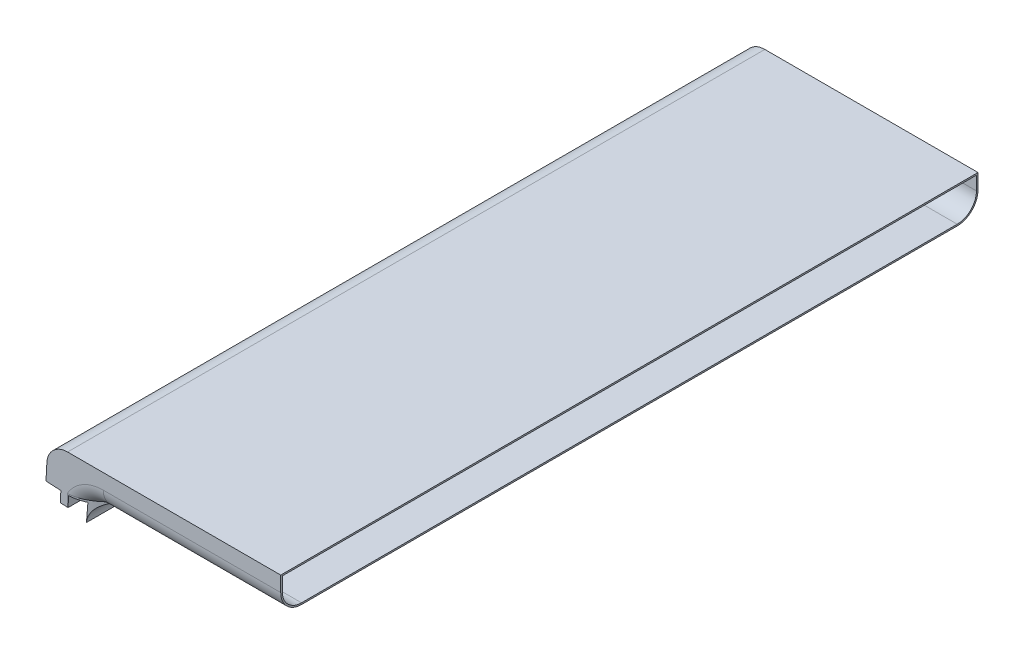
from build123d import *

# Parameters (mm, degrees)
BOSS_EXTRUDE1_DEPTH = 450
FILLET1_R           = 13.4
BOSS_EXTRUDE2_DEPTH = 450
FILLET2_R           = 13.4
CUT_EXTRUDE1_DEPTH  = 451.0000001
SHELL1_T            = -1
BOSS_EXTRUDE3_DEPTH = 450
CUT_EXTRUDE2_DEPTH  = 13.698698186


with BuildPart() as part:
    # Sketch2 → Boss-Extrude1 (new body)
    with BuildSketch(Plane.XY):
        Polygon((0, 0), (151.490860479, 0), (151.490860479, 23.2), (1.215860479, 23.2), align=None)
    extrude(amount=BOSS_EXTRUDE1_DEPTH)

    # Fillet1
    fillet1_edges = [part.edges().sort_by_distance(p)[0] for p in [
        (1.215860479, 23.2, 225),
    ]]
    fillet(fillet1_edges, radius=FILLET1_R)

    # Sketch4 → Boss-Extrude2 (add, through all)
    with BuildSketch(Plane.XY.offset(450)):
        with BuildLine():
            Line((24.166834741, -1.266530141), (23.567700201, -12.698698186))
            ThreePointArc((23.567700201, -12.698698186), (27.725384653, -3.679983428), (36.949335967, 0))
            Line((36.949335967, 0), (0, 0))
            Line((0, 0), (9.586843534, -0.50242518))
            Line((9.586843534, -0.50242518), (9.22049184, -7.492831923))
            Line((9.22049184, -7.492831923), (14.213639514, -7.754511704))
            Line((14.213639514, -7.754511704), (14.579991207, -0.764104961))
            Line((14.579991207, -0.764104961), (24.166834741, -1.266530141))
        make_face()
    extrude(amount=-BOSS_EXTRUDE2_DEPTH)

    # Fillet2
    fillet2_edges = [part.edges().sort_by_distance(p)[0] for p in [
        (27.725384653, -3.679983428, 0),
        (27.725384653, -3.679983428, 450),
        (94.220098223, 0, 450),
        (94.220098223, 0, 0),
    ]]
    fillet(fillet2_edges, radius=FILLET2_R)

    # Sketch5 → Cut-Extrude1 (cut, through all)
    with BuildSketch(Plane.XY):
        with BuildLine():
            Line((24.166834741, -1.266530141), (23.567700201, -12.698698186))
            ThreePointArc((23.567700201, -12.698698186), (27.725384653, -3.679983428), (36.949335967, 0))
            Line((36.949335967, 0), (0, 0))
            Line((0, 0), (9.586843534, -0.50242518))
            Line((9.586843534, -0.50242518), (9.22049184, -7.492831923))
            Line((9.22049184, -7.492831923), (14.213639514, -7.754511704))
            Line((14.213639514, -7.754511704), (14.579991207, -0.764104961))
            Line((14.579991207, -0.764104961), (24.166834741, -1.266530141))
        make_face()
    extrude(amount=CUT_EXTRUDE1_DEPTH, mode=Mode.SUBTRACT)

    # Shell1
    shell1_openings = [part.faces().sort_by_distance(p)[0] for p in [
        (151.490860479, 11.274923044, 225),
    ]]
    offset(amount=SHELL1_T, openings=shell1_openings)

    # Sketch6 → Boss-Extrude3 (add)
    with BuildSketch(Plane.XY):
        with BuildLine():
            Line((24.166834741, -1.266530141), (23.567700201, -12.698698186))
            ThreePointArc((23.567700201, -12.698698186), (27.725384653, -3.679983428), (36.949335967, 0))
            Line((36.949335967, 0), (0, 0))
            Line((0, 0), (9.586843534, -0.50242518))
            Line((9.586843534, -0.50242518), (9.22049184, -7.492831923))
            Line((9.22049184, -7.492831923), (14.213639514, -7.754511704))
            Line((14.213639514, -7.754511704), (14.579991207, -0.764104961))
            Line((14.579991207, -0.764104961), (24.166834741, -1.266530141))
        make_face()
    extrude(amount=BOSS_EXTRUDE3_DEPTH)

    # Sketch7 → Cut-Extrude2 (cut, through all)
    with BuildSketch(Plane.XZ):
        with BuildLine():
            Line((13.739855146, 450), (36.949335967, 450))
            Line((36.949335967, 450), (36.949335967, 436.6))
            add(Edge.make_bspline(
                [(13.739855146, 450), (14.897031698, 450), (16.037346218, 449.888583323), (17.726143963, 449.5782461), (18.285436938, 449.450751492), (19.397111441, 449.150094553), (19.951343846, 448.976153087), (22.667401959, 448.011694289), (24.688899416, 446.937288096), (27.088419743, 445.339458648), (27.560915156, 445.007570641), (28.487586558, 444.326213533), (28.942650844, 443.976156414), (30.286745236, 442.902062513), (31.15469064, 442.154118787), (32.853186658, 440.615831161), (33.683710559, 439.825456971), (35.32594722, 438.223379533), (36.139219776, 437.410115889), (36.949335967, 436.6)],
                knots=[0, 0, 0, 0, 0.125, 0.125, 0.1875, 0.1875, 0.25, 0.25, 0.5, 0.5, 0.5625, 0.5625, 0.625, 0.625, 0.75, 0.75, 0.875, 0.875, 1, 1, 1, 1], degree=3))
        make_face()
        with BuildLine():
            Line((36.949335967, 13.4), (36.949335967, 0))
            Line((36.949335967, 0), (13.739855146, 0))
            add(Edge.make_bspline(
                [(36.949335967, 13.4), (36.139219776, 12.589884111), (35.32594722, 11.776620467), (33.683710559, 10.174543029), (32.853186658, 9.384168839), (31.15469064, 7.845881213), (30.286745236, 7.097937487), (28.942650844, 6.023843586), (28.487586558, 5.673786467), (27.560915156, 4.992429359), (27.088419743, 4.660541352), (24.688899416, 3.062711904), (22.667401959, 1.988305711), (19.951343846, 1.023846913), (19.397111441, 0.849905447), (18.285436938, 0.549248508), (17.726143963, 0.4217539), (16.037346218, 0.111416677), (14.897031698, 0), (13.739855146, 0)],
                knots=[0, 0, 0, 0, 0.125, 0.125, 0.25, 0.25, 0.375, 0.375, 0.4375, 0.4375, 0.5, 0.5, 0.75, 0.75, 0.8125, 0.8125, 0.875, 0.875, 1, 1, 1, 1], degree=3))
        make_face()
    extrude(amount=CUT_EXTRUDE2_DEPTH, mode=Mode.SUBTRACT)


solid = part.part
